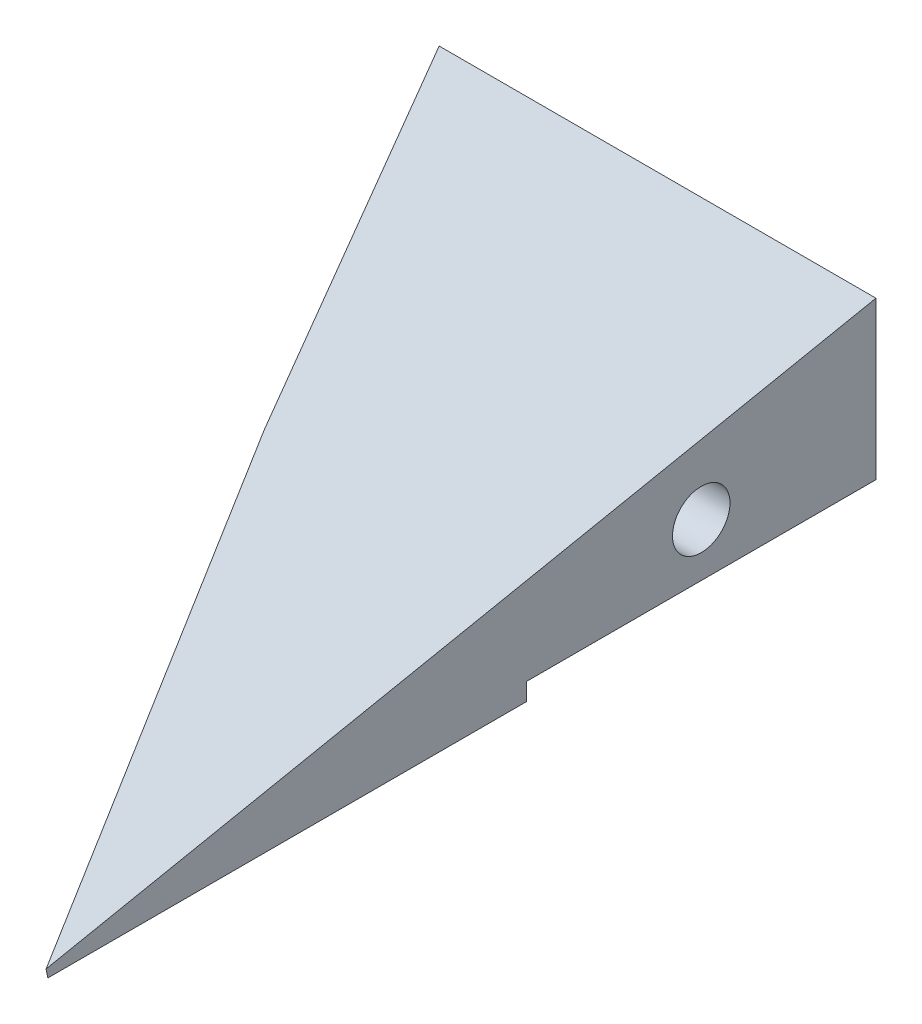
from build123d import *

# Parameters (mm, degrees)
ESBO_O1_W                                      = 130
ESBO_O1_H                                      = 20
RESSALTO_EXTRUS_O1_DEPTH                       = 95
CORTE_EXTRUS_O2_REACH                          = 22
CORTE_EXTRUS_O3_DEPTH                          = 1
CORTE_EXTRUS_O3_DEPTH_BACK                     = 61
BROCA_DE_ROSQUEAR_DE_CANO_PARA_TARRAXA_D_D     = 6.579997
BROCA_DE_ROSQUEAR_DE_CANO_PARA_TARRAXA_D_DEPTH = 10
BROCA_DE_ROSQUEAR_DE_CANO_PARA_TARRAXA_D_TIP   = 1.976830535
BROCA_DE_ROSQUEAR_DE_CANO_PARA_TARRA_2_D       = 6.579997
BROCA_DE_ROSQUEAR_DE_CANO_PARA_TARRA_2_DEPTH   = 10
BROCA_DE_ROSQUEAR_DE_CANO_PARA_TARRA_2_TIP     = 1.976830535
ESBO_O12_W                                     = 50
ESBO_O12_H                                     = 2
CORTE_EXTRUS_O4_DEPTH                          = 40
CORTE_EXTRUS_O5_DEPTH                          = 20.611613514


with BuildPart() as part:
    # Esboço1 → Ressalto-extrusão1 (new body)
    with BuildSketch(Plane.XY):
        Rectangle(ESBO_O1_W, ESBO_O1_H)
    extrude(amount=RESSALTO_EXTRUS_O1_DEPTH)

    # Esboço2 → Corte-extrusão2 (cut, up to next)
    with BuildSketch(Plane(origin=(0, 10, 0), x_dir=(1, 0, 0), z_dir=(0, 1, 0)), mode=Mode.PRIVATE) as corte_extrus_o2_sk1:
        Polygon((15, 0), (-65, 0), (-65, -95), (5, -95), (5, -41), (35, -41), (35, -40), align=None)
    corte_extrus_o2_tool1 = extrude(corte_extrus_o2_sk1.sketch, amount=-CORTE_EXTRUS_O2_REACH, mode=Mode.PRIVATE) & part.part
    add(corte_extrus_o2_tool1.solids().sort_by_distance((-24.897504, 10, 44.887255))[0], mode=Mode.SUBTRACT)

    # Esboço3 → Corte-extrusão3 (cut, two sides)
    with BuildSketch(Plane(origin=(65, 0, 0), x_dir=(0, 0, -1), z_dir=(1, 0, 0))) as corte_extrus_o3_sk:
        Polygon((200.200134404, 50.040026881), (0, 10), (-95, -9), (-295.200134404, -49.040026881), (-375.280188165, 351.360241926), (120.120080642, 450.440295688), align=None)
    extrude(amount=CORTE_EXTRUS_O3_DEPTH, mode=Mode.SUBTRACT)
    extrude(corte_extrus_o3_sk.sketch, amount=-CORTE_EXTRUS_O3_DEPTH_BACK, mode=Mode.SUBTRACT)

    # Broca de rosquear de cano para tarraxa d
    with Locations(Plane(origin=(65, 0, 0), x_dir=(0, 0, -1), z_dir=(1, 0, 0))):
        with Locations((-20, -1.945)):
            Hole(BROCA_DE_ROSQUEAR_DE_CANO_PARA_TARRAXA_D_D / 2, depth=BROCA_DE_ROSQUEAR_DE_CANO_PARA_TARRAXA_D_DEPTH)
            with Locations((0, 0, -(BROCA_DE_ROSQUEAR_DE_CANO_PARA_TARRAXA_D_DEPTH + BROCA_DE_ROSQUEAR_DE_CANO_PARA_TARRAXA_D_TIP / 2))):  # 118° drill point
                Cone(0, BROCA_DE_ROSQUEAR_DE_CANO_PARA_TARRAXA_D_D / 2, BROCA_DE_ROSQUEAR_DE_CANO_PARA_TARRAXA_D_TIP, mode=Mode.SUBTRACT)

    # Broca de rosquear de cano para tarra 2
    with Locations(Plane(origin=(12, 0, -6), x_dir=(0.447213595, 0, 0.894427191), z_dir=(-0.894427191, 0, 0.447213595))):
        with Locations((26.708203932, -1.945)):
            Hole(BROCA_DE_ROSQUEAR_DE_CANO_PARA_TARRA_2_D / 2, depth=BROCA_DE_ROSQUEAR_DE_CANO_PARA_TARRA_2_DEPTH)
            with Locations((0, 0, -(BROCA_DE_ROSQUEAR_DE_CANO_PARA_TARRA_2_DEPTH + BROCA_DE_ROSQUEAR_DE_CANO_PARA_TARRA_2_TIP / 2))):  # 118° drill point
                Cone(0, BROCA_DE_ROSQUEAR_DE_CANO_PARA_TARRA_2_D / 2, BROCA_DE_ROSQUEAR_DE_CANO_PARA_TARRA_2_TIP, mode=Mode.SUBTRACT)

    # Esboço12 → Corte-extrusão4 (cut)
    with BuildSketch(Plane(origin=(0, 0, 0), x_dir=(-1, 0, 0), z_dir=(0, 0, -1))):
        with Locations((-40, -9)):
            Rectangle(ESBO_O12_W, ESBO_O12_H)
    extrude(amount=-CORTE_EXTRUS_O4_DEPTH, mode=Mode.SUBTRACT)

    # Esboço13 → Corte-extrusão5 (cut, through all)
    with BuildSketch(Plane(origin=(0, 9.615384615, 1.923076923), x_dir=(1, 0, 0), z_dir=(0, 0.980580676, 0.196116135))):
        Polygon((35, -38.830994757), (65, -94.920209407), (66.558450481, -100.096318767), (-6.379545029, -94.920209407), (-1.820755469, -30.681038758), (34.269484804, -39.561509954), align=None)
    extrude(amount=-CORTE_EXTRUS_O5_DEPTH, mode=Mode.SUBTRACT)


solid = part.part
